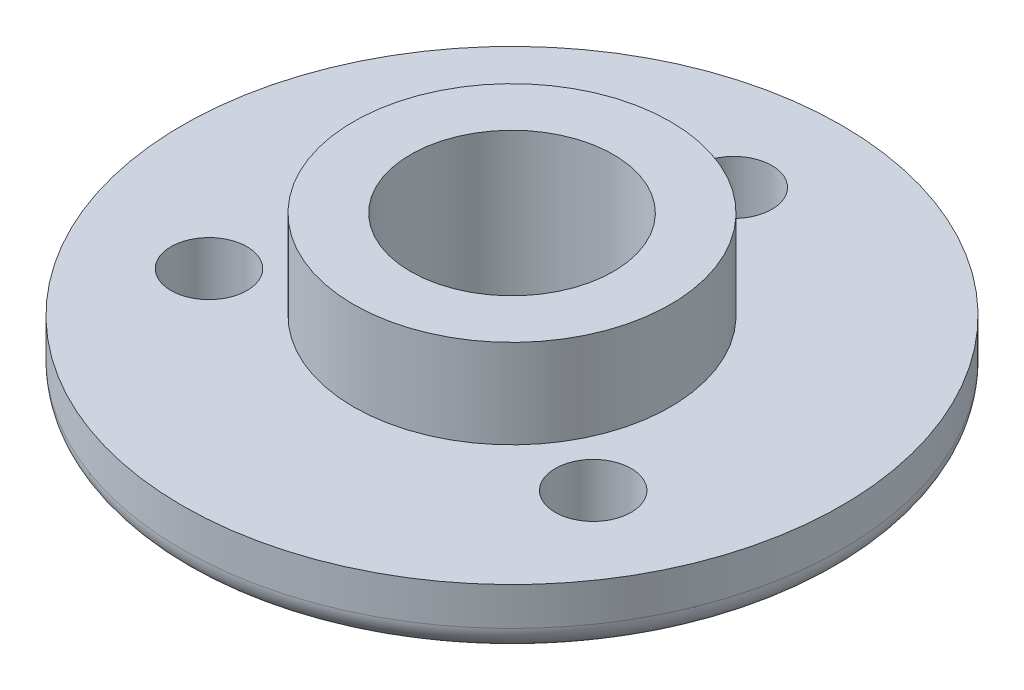
from build123d import *

# Parameters (mm, degrees)
SKETCH1_R               = 26
BOSS_EXTRUDE1_DEPTH     = 5
CUT_EXTRUDE1_DEPTH      = 38.107950631
CUT_EXTRUDE1_DEPTH_BACK = 38.107950631
SKETCH1_3_R             = 3
SKETCH1_4_R             = 12.5
BOSS_EXTRUDE2_DEPTH     = 12
CUT_EXTRUDE2_DEPTH      = 39.678159212
CUT_EXTRUDE2_DEPTH_BACK = 39.678159212
SKETCH1_5_R             = 8
FILLET1_R               = 2


with BuildPart() as part:
    # Sketch1 → Boss-Extrude1 (new body)
    with BuildSketch(Plane(origin=(0, 0, 0), x_dir=(1, 0, 0), z_dir=(0, 1, 0))):
        Circle(SKETCH1_R)
    extrude(amount=BOSS_EXTRUDE1_DEPTH)

    # Sketch1_3 → Cut-Extrude1 (cut, two sides: drawn at the far end of the back side and taken through both)
    with BuildSketch(Plane(origin=(0, 0, 0), x_dir=(1, 0, 0), z_dir=(0, 1, 0)).offset(-CUT_EXTRUDE1_DEPTH_BACK)):
        with Locations((0, 17.5)):
            Circle(SKETCH1_3_R)
        with Locations((15.155444566, -8.75)):
            Circle(SKETCH1_3_R)
        with Locations((-15.155444566, -8.75)):
            Circle(SKETCH1_3_R)
    extrude(amount=CUT_EXTRUDE1_DEPTH + CUT_EXTRUDE1_DEPTH_BACK, mode=Mode.SUBTRACT)

    # Sketch1_4 → Boss-Extrude2 (add)
    with BuildSketch(Plane(origin=(0, 0, 0), x_dir=(1, 0, 0), z_dir=(0, 1, 0))):
        Circle(SKETCH1_4_R)
    extrude(amount=BOSS_EXTRUDE2_DEPTH)

    # Sketch1_5 → Cut-Extrude2 (cut, two sides: drawn at the far end of the back side and taken through both)
    with BuildSketch(Plane(origin=(0, 0, 0), x_dir=(1, 0, 0), z_dir=(0, 1, 0)).offset(-CUT_EXTRUDE2_DEPTH_BACK)):
        Circle(SKETCH1_5_R)
    extrude(amount=CUT_EXTRUDE2_DEPTH + CUT_EXTRUDE2_DEPTH_BACK, mode=Mode.SUBTRACT)

    # Fillet1
    fillet1_edges = [part.edges().sort_by_distance(p)[0] for p in [
        (-26, 0, 0),
    ]]
    fillet(fillet1_edges, radius=FILLET1_R)


solid = part.part
